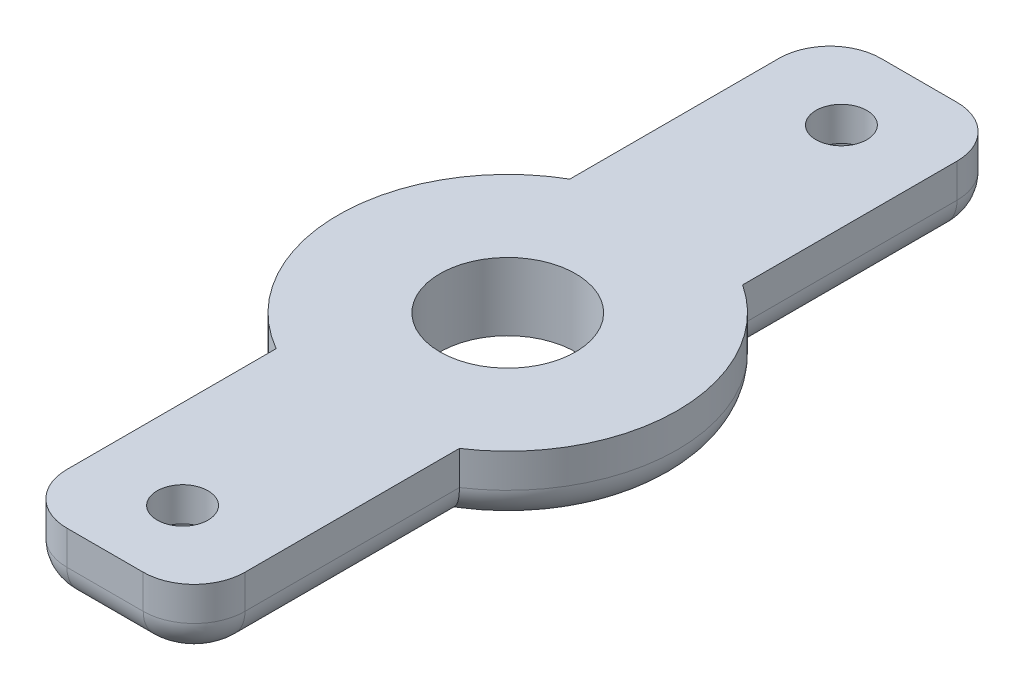
from build123d import *

# Parameters (mm, degrees)
SKETCH1_R           = 4
BOSS_EXTRUDE1_DEPTH = 4
SKETCH2_R           = 1.5
CUT_EXTRUDE1_DEPTH  = 10
SKETCH3_R           = 2.5
CUT_EXTRUDE2_DEPTH  = 2
SKETCH4_R           = 10
SKETCH4_R_2         = 4
BOSS_EXTRUDE3_DEPTH = 4
FILLET1_R           = 2


with BuildPart() as part:
    # Sketch1 → Boss-Extrude1 (new body)
    with BuildSketch(Plane(origin=(0, 0, 0), x_dir=(1, 0, 0), z_dir=(0, 1, 0))):
        with BuildLine():
            Line((5.25, -21), (5.25, 21))
            ThreePointArc((5.25, 21), (4.371320344, 23.121320344), (2.25, 24))
            Line((2.25, 24), (-2.25, 24))
            ThreePointArc((-2.25, 24), (-4.371320344, 23.121320344), (-5.25, 21))
            Line((-5.25, 21), (-5.25, -21))
            ThreePointArc((-5.25, -21), (-4.371320344, -23.121320344), (-2.25, -24))
            Line((-2.25, -24), (2.25, -24))
            ThreePointArc((2.25, -24), (4.371320344, -23.121320344), (5.25, -21))
        make_face()
        with Locations((-0.25, 0)):
            Circle(SKETCH1_R, mode=Mode.SUBTRACT)
    extrude(amount=BOSS_EXTRUDE1_DEPTH)

    # Sketch2 → Cut-Extrude1 (cut)
    with BuildSketch(Plane.XZ):
        with Locations((0, 19.428521822)):
            Circle(SKETCH2_R)
        with Locations((0, -19.428521822)):
            Circle(SKETCH2_R)
    extrude(amount=-CUT_EXTRUDE1_DEPTH, mode=Mode.SUBTRACT)

    # Sketch3 → Cut-Extrude2 (cut)
    with BuildSketch(Plane.XZ):
        with Locations((0, 19.428521822)):
            Circle(SKETCH3_R)
        with Locations((0, -19.428521822)):
            Circle(SKETCH3_R)
    extrude(amount=-CUT_EXTRUDE2_DEPTH, mode=Mode.SUBTRACT)

    # Sketch4 → Boss-Extrude3 (add)
    with BuildSketch(Plane.XZ):
        with Locations((-0.25, 0)):
            Circle(SKETCH4_R)
        with Locations((-0.25, 0)):
            Circle(SKETCH4_R_2, mode=Mode.SUBTRACT)
    extrude(amount=-BOSS_EXTRUDE3_DEPTH)

    # Fillet1
    fillet1_edges = [part.edges().sort_by_distance(p)[0] for p in [
        (5.25, 0, 14.675823272),
        (4.371320344, 0, 23.121320344),
        (-5.25, 0, 14.830127019),
        (5.25, 0, -14.675823272),
        (9.75, 0, 0),
        (-10.25, 0, 0),
        (0, 0, 24),
        (-4.371320344, 0, 23.121320344),
        (-5.25, 0, -14.830127019),
        (-4.371320344, 0, -23.121320344),
        (0, 0, -24),
        (4.371320344, 0, -23.121320344),
    ]]
    fillet(fillet1_edges, radius=FILLET1_R)


solid = part.part
